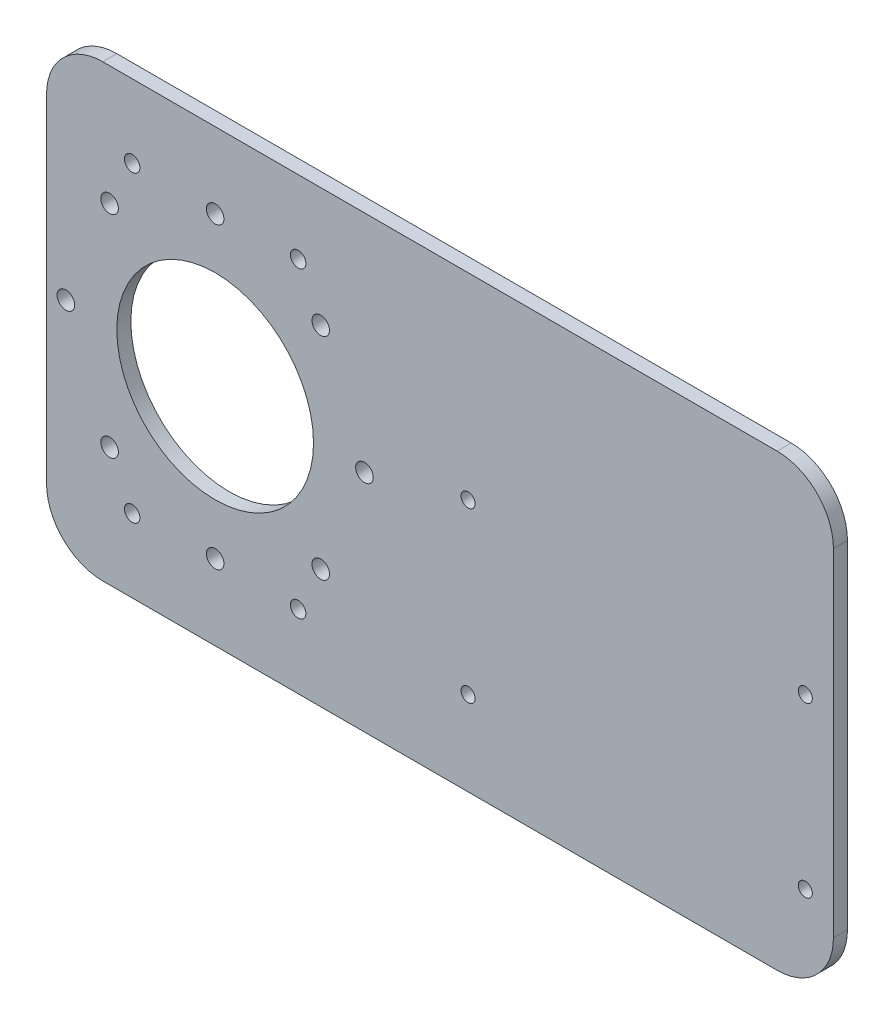
from build123d import *

# Parameters (mm, degrees)
SKETCH1_W           = 355.6
SKETCH1_H           = 203.2
BOSS_EXTRUDE1_DEPTH = 6.35
SKETCH2_R           = 44.45
SKETCH2_R_2         = 3.96875
CUT_EXTRUDE1_DEPTH  = 76.2
SKETCH3_R           = 3.50012
CUT_EXTRUDE2_DEPTH  = 6.35
FILLET1_R           = 25.4
SKETCH5_R           = 3.175
CUT_EXTRUDE4_DEPTH  = 6.35


with BuildPart() as part:
    # Sketch1 → Boss-Extrude1 (new body)
    with BuildSketch(Plane.XY):
        with Locations((177.8, 101.6)):
            Rectangle(SKETCH1_W, SKETCH1_H)
    extrude(amount=BOSS_EXTRUDE1_DEPTH)

    # Sketch2 → Cut-Extrude1 (cut)
    with BuildSketch(Plane.XY.offset(6.35)):
        with Locations((76.2, 101.6)):
            Circle(SKETCH2_R)
        with Locations((143.66875, 101.6)):
            Circle(SKETCH2_R_2)
        with Locations((123.907610643, 53.892389357)):
            Circle(SKETCH2_R_2)
        with Locations((76.2, 34.13125)):
            Circle(SKETCH2_R_2)
        with Locations((28.492389357, 53.892389357)):
            Circle(SKETCH2_R_2)
        with Locations((8.73125, 101.6)):
            Circle(SKETCH2_R_2)
        with Locations((28.492389357, 149.307610643)):
            Circle(SKETCH2_R_2)
        with Locations((76.2, 169.06875)):
            Circle(SKETCH2_R_2)
        with Locations((123.907610643, 149.307610643)):
            Circle(SKETCH2_R_2)
    extrude(amount=-CUT_EXTRUDE1_DEPTH, mode=Mode.SUBTRACT)

    # Sketch3 → Cut-Extrude2 (cut)
    with BuildSketch(Plane.XY.offset(6.35)):
        with Locations((38.69944, 170.09999)):
            Circle(SKETCH3_R)
        with Locations((113.70056, 170.09999)):
            Circle(SKETCH3_R)
        with Locations((113.70056, 33.10001)):
            Circle(SKETCH3_R)
        with Locations((38.69944, 33.10001)):
            Circle(SKETCH3_R)
    extrude(amount=-CUT_EXTRUDE2_DEPTH, mode=Mode.SUBTRACT)

    # Fillet1
    fillet1_edges = [part.edges().sort_by_distance(p)[0] for p in [
        (0, 203.2, 3.175),
        (355.6, 203.2, 3.175),
        (355.6, 0, 3.175),
        (0, 0, 3.175),
    ]]
    fillet(fillet1_edges, radius=FILLET1_R)

    # Sketch5 → Cut-Extrude4 (cut)
    with BuildSketch(Plane(origin=(0, 0, 0), x_dir=(-1, 0, 0), z_dir=(0, 0, -1))):
        with Locations((-342.9, 114.3)):
            Circle(SKETCH5_R)
        with Locations((-190.5, 114.3)):
            Circle(SKETCH5_R)
        with Locations((-190.5, 38.1)):
            Circle(SKETCH5_R)
        with Locations((-342.9, 38.1)):
            Circle(SKETCH5_R)
    extrude(amount=-CUT_EXTRUDE4_DEPTH, mode=Mode.SUBTRACT)


solid = part.part
